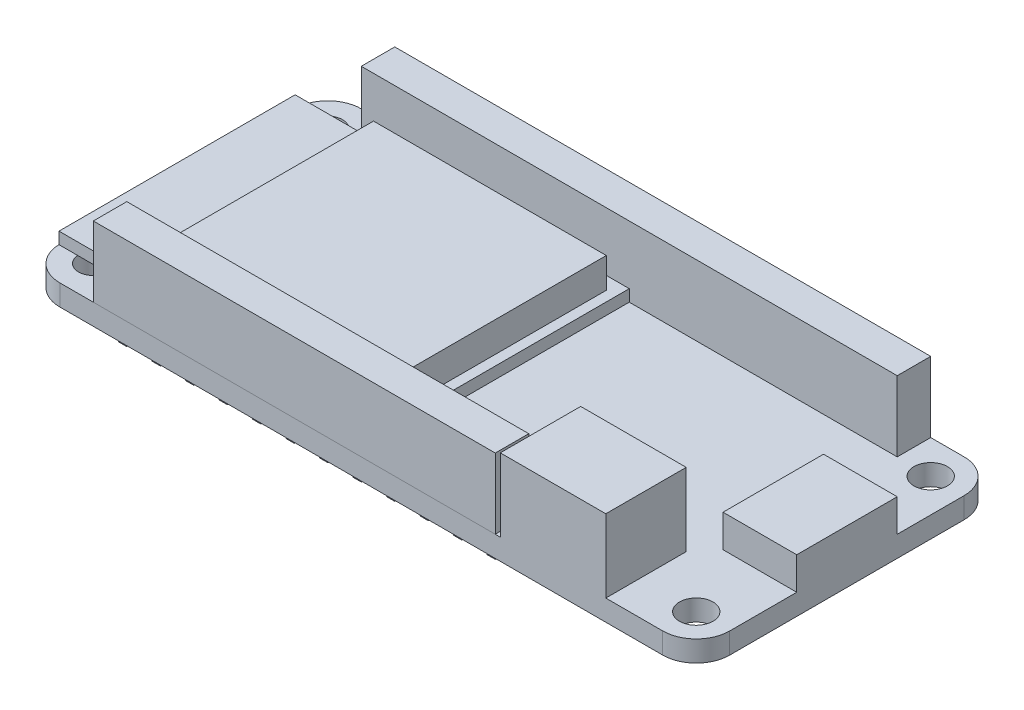
from build123d import *

# Parameters (mm, degrees)
SKETCH1_R              = 1.27
SKETCH1_R_2            = 1.1176
BOSS_EXTRUDE1_DEPTH    = 1.5875
SKETCH2_W              = 25.4
SKETCH2_H              = 17.907
BOSS_EXTRUDE2_DEPTH    = 0.889
BOSS_EXTRUDE3_START    = 0.889
SKETCH2_3_W            = 17.653
SKETCH2_3_H            = 15.8242
BOSS_EXTRUDE3_DEPTH    = 2.286
SKETCH2_4_W            = 8.001
SKETCH2_4_H            = 6.096
BOSS_EXTRUDE4_DEPTH    = 5.5372
SKETCH2_5_W            = 5.588
SKETCH2_5_H            = 7.62
BOSS_EXTRUDE5_DEPTH    = 2.4638
SKETCH3_W              = 0.635
SKETCH3_H              = 0.635
BOSS_EXTRUDE6_DEPTH    = 1.016
BOSS_EXTRUDE6_2_DEPTH  = 1.016
BOSS_EXTRUDE6_3_DEPTH  = 1.016
BOSS_EXTRUDE6_4_DEPTH  = 1.016
BOSS_EXTRUDE6_5_DEPTH  = 1.016
BOSS_EXTRUDE6_6_DEPTH  = 1.016
BOSS_EXTRUDE6_7_DEPTH  = 1.016
BOSS_EXTRUDE6_8_DEPTH  = 1.016
BOSS_EXTRUDE6_9_DEPTH  = 1.016
BOSS_EXTRUDE6_10_DEPTH = 1.016
BOSS_EXTRUDE6_11_DEPTH = 1.016
BOSS_EXTRUDE6_12_DEPTH = 1.016
BOSS_EXTRUDE6_13_DEPTH = 1.016
BOSS_EXTRUDE6_14_DEPTH = 1.016
BOSS_EXTRUDE6_15_DEPTH = 1.016
BOSS_EXTRUDE6_16_DEPTH = 1.016
BOSS_EXTRUDE6_17_DEPTH = 1.016
BOSS_EXTRUDE6_18_DEPTH = 1.016
BOSS_EXTRUDE6_19_DEPTH = 1.016
BOSS_EXTRUDE6_20_DEPTH = 1.016
BOSS_EXTRUDE6_21_DEPTH = 1.016
BOSS_EXTRUDE6_22_DEPTH = 1.016
BOSS_EXTRUDE6_23_DEPTH = 1.016
BOSS_EXTRUDE6_24_DEPTH = 1.016
BOSS_EXTRUDE6_25_DEPTH = 1.016
BOSS_EXTRUDE6_26_DEPTH = 1.016
BOSS_EXTRUDE6_27_DEPTH = 1.016
BOSS_EXTRUDE6_28_DEPTH = 1.016
SKETCH4_W              = 30.48
SKETCH4_H              = 2.54
BOSS_EXTRUDE7_DEPTH    = 5.334
SKETCH4_W_2            = 40.64
BOSS_EXTRUDE7_2_DEPTH  = 5.334


with BuildPart() as part:
    # Sketch1 → Boss-Extrude1 (new body)
    with BuildSketch(Plane(origin=(0, 0, 0), x_dir=(1, 0, 0), z_dir=(0, 1, 0))):
        with BuildLine():
            Line((2.54, 0), (48.26, 0))
            ThreePointArc((48.26, 0), (50.056051224, 0.743948776), (50.8, 2.54))
            Line((50.8, 2.54), (50.8, 20.32))
            ThreePointArc((50.8, 20.32), (50.056051224, 22.116051224), (48.26, 22.86))
            Line((48.26, 22.86), (2.54, 22.86))
            ThreePointArc((2.54, 22.86), (0.743948776, 22.116051224), (0, 20.32))
            Line((0, 20.32), (0, 2.54))
            ThreePointArc((0, 2.54), (0.743948776, 0.743948776), (2.54, 0))
        make_face()
        with Locations((48.26, 20.32)):
            Circle(SKETCH1_R, mode=Mode.SUBTRACT)
        with Locations((48.26, 2.54)):
            Circle(SKETCH1_R, mode=Mode.SUBTRACT)
        with Locations((2.54, 20.32)):
            Circle(SKETCH1_R_2, mode=Mode.SUBTRACT)
        with Locations((2.54, 2.54)):
            Circle(SKETCH1_R_2, mode=Mode.SUBTRACT)
    extrude(amount=BOSS_EXTRUDE1_DEPTH)

    # Sketch2 → Boss-Extrude2 (add)
    with BuildSketch(Plane(origin=(0, 1.5875, 1.5875), x_dir=(1, 0, 0), z_dir=(0, 1, 0))):
        with Locations((12.7, 13.0175)):
            Rectangle(SKETCH2_W, SKETCH2_H)
    extrude(amount=BOSS_EXTRUDE2_DEPTH)

    # Sketch2_3 → Boss-Extrude3 (add)
    with BuildSketch(Plane(origin=(0, 1.5875, 1.5875), x_dir=(1, 0, 0), z_dir=(0, 1, 0)).offset(BOSS_EXTRUDE3_START)):
        with Locations((15.8115, 13.0175)):
            Rectangle(SKETCH2_3_W, SKETCH2_3_H)
    extrude(amount=BOSS_EXTRUDE3_DEPTH)

    # Sketch2_4 → Boss-Extrude4 (add)
    with BuildSketch(Plane(origin=(0, 1.5875, 1.5875), x_dir=(1, 0, 0), z_dir=(0, 1, 0))):
        with Locations((39.9415, 4.6355)):
            Rectangle(SKETCH2_4_W, SKETCH2_4_H)
    extrude(amount=BOSS_EXTRUDE4_DEPTH)

    # Sketch2_5 → Boss-Extrude5 (add)
    with BuildSketch(Plane(origin=(0, 1.5875, 1.5875), x_dir=(1, 0, 0), z_dir=(0, 1, 0))):
        with Locations((48.006, 13.0175)):
            Rectangle(SKETCH2_5_W, SKETCH2_5_H)
    extrude(amount=BOSS_EXTRUDE5_DEPTH)


with BuildPart() as body_2:
    # Sketch3 → Boss-Extrude6 (new body)
    with BuildSketch(Plane.XZ):
        with Locations((8.89, -21.59)):
            Rectangle(SKETCH3_W, SKETCH3_H)
    extrude(amount=BOSS_EXTRUDE6_DEPTH)


with BuildPart() as body_3:
    # Sketch3 → Boss-Extrude6 2 (new body)
    with BuildSketch(Plane.XZ):
        with Locations((6.35, -21.59)):
            Rectangle(SKETCH3_W, SKETCH3_H)
    extrude(amount=BOSS_EXTRUDE6_2_DEPTH)


with BuildPart() as body_4:
    # Sketch3 → Boss-Extrude6 3 (new body)
    with BuildSketch(Plane.XZ):
        with Locations((11.43, -21.59)):
            Rectangle(SKETCH3_W, SKETCH3_H)
    extrude(amount=BOSS_EXTRUDE6_3_DEPTH)


with BuildPart() as body_5:
    # Sketch3 → Boss-Extrude6 4 (new body)
    with BuildSketch(Plane.XZ):
        with Locations((13.97, -21.59)):
            Rectangle(SKETCH3_W, SKETCH3_H)
    extrude(amount=BOSS_EXTRUDE6_4_DEPTH)


with BuildPart() as body_6:
    # Sketch3 → Boss-Extrude6 5 (new body)
    with BuildSketch(Plane.XZ):
        with Locations((16.51, -21.59)):
            Rectangle(SKETCH3_W, SKETCH3_H)
    extrude(amount=BOSS_EXTRUDE6_5_DEPTH)


with BuildPart() as body_7:
    # Sketch3 → Boss-Extrude6 6 (new body)
    with BuildSketch(Plane.XZ):
        with Locations((19.05, -21.59)):
            Rectangle(SKETCH3_W, SKETCH3_H)
    extrude(amount=BOSS_EXTRUDE6_6_DEPTH)


with BuildPart() as body_8:
    # Sketch3 → Boss-Extrude6 7 (new body)
    with BuildSketch(Plane.XZ):
        with Locations((21.59, -21.59)):
            Rectangle(SKETCH3_W, SKETCH3_H)
    extrude(amount=BOSS_EXTRUDE6_7_DEPTH)


with BuildPart() as body_9:
    # Sketch3 → Boss-Extrude6 8 (new body)
    with BuildSketch(Plane.XZ):
        with Locations((24.13, -21.59)):
            Rectangle(SKETCH3_W, SKETCH3_H)
    extrude(amount=BOSS_EXTRUDE6_8_DEPTH)


with BuildPart() as body_10:
    # Sketch3 → Boss-Extrude6 9 (new body)
    with BuildSketch(Plane.XZ):
        with Locations((26.67, -21.59)):
            Rectangle(SKETCH3_W, SKETCH3_H)
    extrude(amount=BOSS_EXTRUDE6_9_DEPTH)


with BuildPart() as body_11:
    # Sketch3 → Boss-Extrude6 10 (new body)
    with BuildSketch(Plane.XZ):
        with Locations((29.21, -21.59)):
            Rectangle(SKETCH3_W, SKETCH3_H)
    extrude(amount=BOSS_EXTRUDE6_10_DEPTH)


with BuildPart() as body_12:
    # Sketch3 → Boss-Extrude6 11 (new body)
    with BuildSketch(Plane.XZ):
        with Locations((31.75, -21.59)):
            Rectangle(SKETCH3_W, SKETCH3_H)
    extrude(amount=BOSS_EXTRUDE6_11_DEPTH)


with BuildPart() as body_13:
    # Sketch3 → Boss-Extrude6 12 (new body)
    with BuildSketch(Plane.XZ):
        with Locations((34.29, -21.59)):
            Rectangle(SKETCH3_W, SKETCH3_H)
    extrude(amount=BOSS_EXTRUDE6_12_DEPTH)


with BuildPart() as body_14:
    # Sketch3 → Boss-Extrude6 13 (new body)
    with BuildSketch(Plane.XZ):
        with Locations((36.83, -21.59)):
            Rectangle(SKETCH3_W, SKETCH3_H)
    extrude(amount=BOSS_EXTRUDE6_13_DEPTH)


with BuildPart() as body_15:
    # Sketch3 → Boss-Extrude6 14 (new body)
    with BuildSketch(Plane.XZ):
        with Locations((39.37, -21.59)):
            Rectangle(SKETCH3_W, SKETCH3_H)
    extrude(amount=BOSS_EXTRUDE6_14_DEPTH)


with BuildPart() as body_16:
    # Sketch3 → Boss-Extrude6 15 (new body)
    with BuildSketch(Plane.XZ):
        with Locations((41.91, -21.59)):
            Rectangle(SKETCH3_W, SKETCH3_H)
    extrude(amount=BOSS_EXTRUDE6_15_DEPTH)


with BuildPart() as body_17:
    # Sketch3 → Boss-Extrude6 16 (new body)
    with BuildSketch(Plane.XZ):
        with Locations((44.45, -21.59)):
            Rectangle(SKETCH3_W, SKETCH3_H)
    extrude(amount=BOSS_EXTRUDE6_16_DEPTH)


with BuildPart() as body_18:
    # Sketch3 → Boss-Extrude6 17 (new body)
    with BuildSketch(Plane.XZ):
        with Locations((8.89, -1.27)):
            Rectangle(SKETCH3_W, SKETCH3_H)
    extrude(amount=BOSS_EXTRUDE6_17_DEPTH)


with BuildPart() as body_19:
    # Sketch3 → Boss-Extrude6 18 (new body)
    with BuildSketch(Plane.XZ):
        with Locations((6.35, -1.27)):
            Rectangle(SKETCH3_W, SKETCH3_H)
    extrude(amount=BOSS_EXTRUDE6_18_DEPTH)


with BuildPart() as body_20:
    # Sketch3 → Boss-Extrude6 19 (new body)
    with BuildSketch(Plane.XZ):
        with Locations((11.43, -1.27)):
            Rectangle(SKETCH3_W, SKETCH3_H)
    extrude(amount=BOSS_EXTRUDE6_19_DEPTH)


with BuildPart() as body_21:
    # Sketch3 → Boss-Extrude6 20 (new body)
    with BuildSketch(Plane.XZ):
        with Locations((13.97, -1.27)):
            Rectangle(SKETCH3_W, SKETCH3_H)
    extrude(amount=BOSS_EXTRUDE6_20_DEPTH)


with BuildPart() as body_22:
    # Sketch3 → Boss-Extrude6 21 (new body)
    with BuildSketch(Plane.XZ):
        with Locations((16.51, -1.27)):
            Rectangle(SKETCH3_W, SKETCH3_H)
    extrude(amount=BOSS_EXTRUDE6_21_DEPTH)


with BuildPart() as body_23:
    # Sketch3 → Boss-Extrude6 22 (new body)
    with BuildSketch(Plane.XZ):
        with Locations((19.05, -1.27)):
            Rectangle(SKETCH3_W, SKETCH3_H)
    extrude(amount=BOSS_EXTRUDE6_22_DEPTH)


with BuildPart() as body_24:
    # Sketch3 → Boss-Extrude6 23 (new body)
    with BuildSketch(Plane.XZ):
        with Locations((21.59, -1.27)):
            Rectangle(SKETCH3_W, SKETCH3_H)
    extrude(amount=BOSS_EXTRUDE6_23_DEPTH)


with BuildPart() as body_25:
    # Sketch3 → Boss-Extrude6 24 (new body)
    with BuildSketch(Plane.XZ):
        with Locations((24.13, -1.27)):
            Rectangle(SKETCH3_W, SKETCH3_H)
    extrude(amount=BOSS_EXTRUDE6_24_DEPTH)


with BuildPart() as body_26:
    # Sketch3 → Boss-Extrude6 25 (new body)
    with BuildSketch(Plane.XZ):
        with Locations((26.67, -1.27)):
            Rectangle(SKETCH3_W, SKETCH3_H)
    extrude(amount=BOSS_EXTRUDE6_25_DEPTH)


with BuildPart() as body_27:
    # Sketch3 → Boss-Extrude6 26 (new body)
    with BuildSketch(Plane.XZ):
        with Locations((29.21, -1.27)):
            Rectangle(SKETCH3_W, SKETCH3_H)
    extrude(amount=BOSS_EXTRUDE6_26_DEPTH)


with BuildPart() as body_28:
    # Sketch3 → Boss-Extrude6 27 (new body)
    with BuildSketch(Plane.XZ):
        with Locations((31.75, -1.27)):
            Rectangle(SKETCH3_W, SKETCH3_H)
    extrude(amount=BOSS_EXTRUDE6_27_DEPTH)


with BuildPart() as body_29:
    # Sketch3 → Boss-Extrude6 28 (new body)
    with BuildSketch(Plane.XZ):
        with Locations((34.29, -1.27)):
            Rectangle(SKETCH3_W, SKETCH3_H)
    extrude(amount=BOSS_EXTRUDE6_28_DEPTH)


with BuildPart() as body_30:
    # Sketch4 → Boss-Extrude7 (new body)
    with BuildSketch(Plane(origin=(0, 1.5875, 0), x_dir=(1, 0, 0), z_dir=(0, 1, 0))):
        with Locations((20.32, 1.27)):
            Rectangle(SKETCH4_W, SKETCH4_H)
    extrude(amount=BOSS_EXTRUDE7_DEPTH)


with BuildPart() as body_31:
    # Sketch4 → Boss-Extrude7 2 (new body)
    with BuildSketch(Plane(origin=(0, 1.5875, 0), x_dir=(1, 0, 0), z_dir=(0, 1, 0))):
        with Locations((25.4, 21.59)):
            Rectangle(SKETCH4_W_2, SKETCH4_H)
    extrude(amount=BOSS_EXTRUDE7_2_DEPTH)


solid = Compound([part.part, body_2.part, body_3.part, body_4.part, body_5.part, body_6.part, body_7.part, body_8.part, body_9.part, body_10.part, body_11.part, body_12.part, body_13.part, body_14.part, body_15.part, body_16.part, body_17.part, body_18.part, body_19.part, body_20.part, body_21.part, body_22.part, body_23.part, body_24.part, body_25.part, body_26.part, body_27.part, body_28.part, body_29.part, body_30.part, body_31.part])
